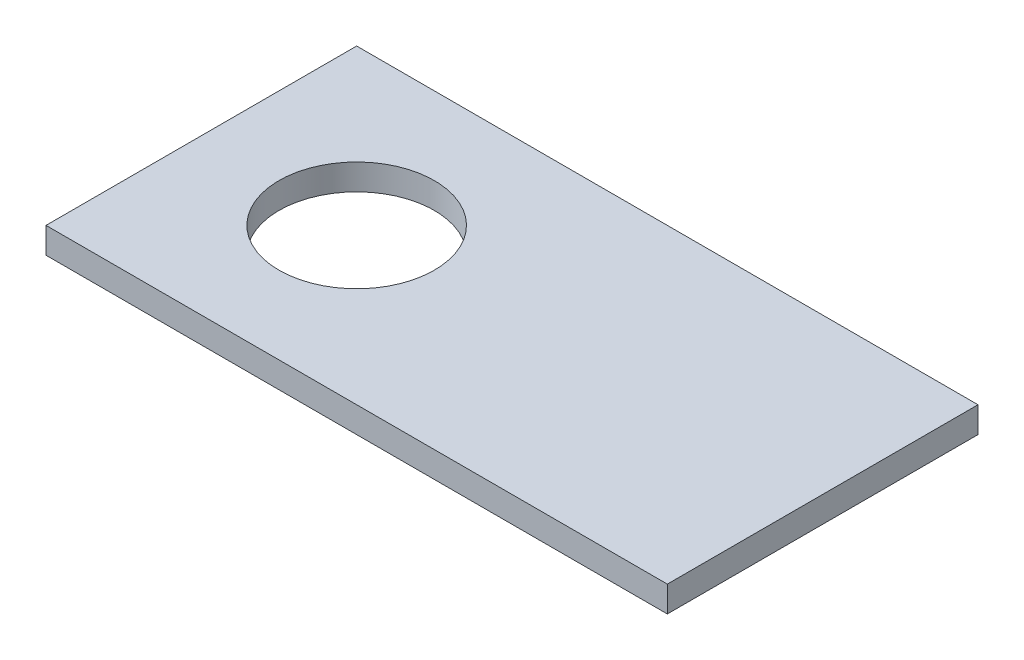
from build123d import *

# Parameters (mm, degrees)
SKETCH1_W           = 76.2
SKETCH1_H           = 38.1
SKETCH1_R           = 9.525
BOSS_EXTRUDE1_DEPTH = 3.175


with BuildPart() as part:
    # Sketch1 → Boss-Extrude1 (new body)
    with BuildSketch(Plane(origin=(0, 0, 0), x_dir=(1, 0, 0), z_dir=(0, 1, 0))):
        with Locations((-19.05, 0)):
            Rectangle(SKETCH1_W, SKETCH1_H)
        with Locations(Location((-38.1, 0, 0), (0, 0, 270))):  # turned: the seam where the file's is
            Circle(SKETCH1_R, mode=Mode.SUBTRACT)
    extrude(amount=BOSS_EXTRUDE1_DEPTH)


solid = part.part
